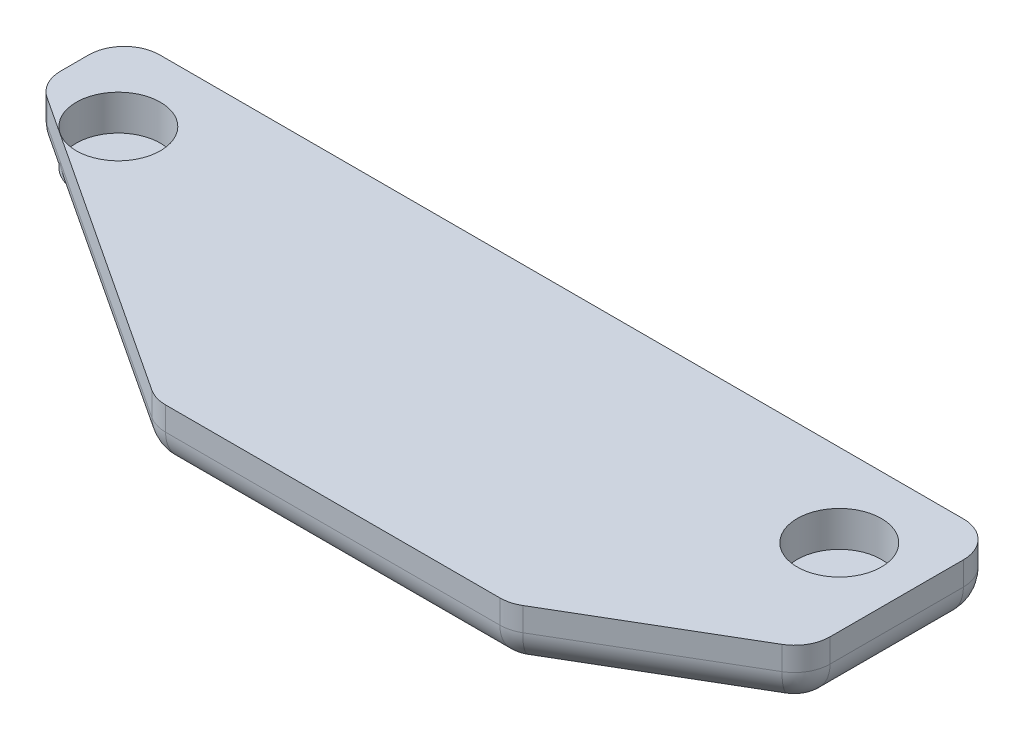
from build123d import *

# Parameters (mm, degrees)
BOSS_EXTRUDE1_DEPTH = 2.5
SKETCH4_R           = 1.78
CUT_EXTRUDE1_DEPTH  = 1.5
FILLET1_R           = 1.5


with BuildPart() as part:
    # Sketch2 → Boss-Extrude1 (new body)
    with BuildSketch(Plane(origin=(0, 0, 0), x_dir=(1, 0, 0), z_dir=(0, 1, 0))):
        Polygon((-21.216153836, 11.741903429), (-21.216153836, 8.241903429), (-7.216153836, -0.958096571), (7.783846164, -0.958096571), (15.783846164, 3.741903429), (15.783846164, 11.741903429), align=None)
    extrude(amount=BOSS_EXTRUDE1_DEPTH)

    # Sketch4 → Cut-Extrude1 (cut)
    with BuildSketch(Plane(origin=(0, 2.5, 0), x_dir=(1, 0, 0), z_dir=(0, 1, 0))):
        with Locations((-17.966153836, 8.241903429)):
            Circle(SKETCH4_R)
        with Locations((12.533846164, 8.241903429)):
            Circle(SKETCH4_R)
    extrude(amount=-CUT_EXTRUDE1_DEPTH, mode=Mode.SUBTRACT)

    # Fillet1
    fillet1_edges = [part.edges().sort_by_distance(p)[0] for p in [
        (15.783846164, 1.25, -11.741903429),
        (15.783846164, 1.25, -3.741903429),
        (7.783846164, 1.25, 0.958096571),
        (-7.216153836, 1.25, 0.958096571),
        (-21.216153836, 1.25, -8.241903429),
        (-21.216153836, 1.25, -11.741903429),
        (15.783846164, 0, -7.741903429),
        (11.783846164, 0, -1.391903429),
        (0.283846164, 0, 0.958096571),
        (-14.216153836, 0, -3.641903429),
        (-21.216153836, 0, -9.991903429),
        (-2.716153836, 0, -11.741903429),
    ]]
    fillet(fillet1_edges, radius=FILLET1_R)


solid = part.part
